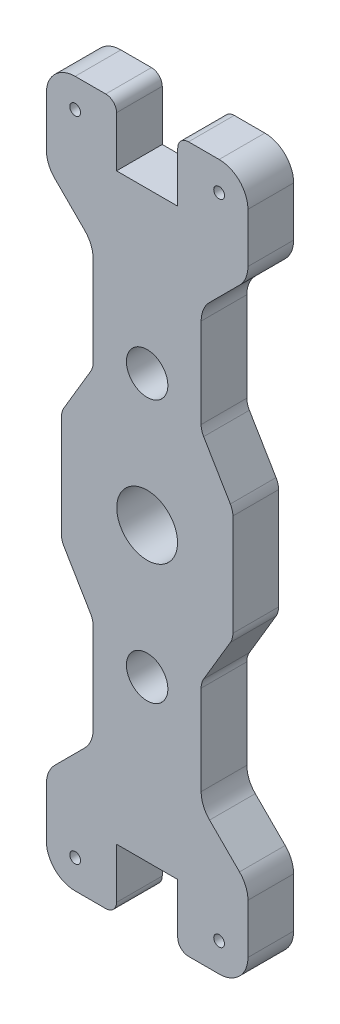
from build123d import *

# Parameters (mm, degrees)
SKETCH1_R                = 8.4375
SKETCH1_R_2              = 1.5
BOSS_EXTRUDE1_DEPTH      = 6.35
FILLET1_R                = 8
F_7_16_CLEARANCE_HOLE4_D = 11.50874
BOSS_EXTRUDE2_DEPTH      = 12.7
FILLET2_R                = 5


with BuildPart() as part:
    # Sketch1 → Boss-Extrude1 (new body, symmetric)
    with BuildSketch(Plane.XY):
        with BuildLine():
            Line((-28, 72.922835534), (-28, 90))
            ThreePointArc((-28, 90), (-25.656854249, 95.656854249), (-20, 98))
            Line((-20, 98), (-11.5, 98))
            ThreePointArc((-11.5, 98), (-9.378679656, 97.121320344), (-8.5, 95))
            Line((-8.5, 95), (-8.5, 81))
            Line((-8.5, 81), (8.5, 81))
            Line((8.5, 81), (8.5, 95))
            ThreePointArc((8.5, 95), (9.378679656, 97.121320344), (11.5, 98))
            Line((11.5, 98), (20, 98))
            ThreePointArc((20, 98), (25.656854249, 95.656854249), (28, 90))
            Line((28, 90), (28, 72.922835534))
            Line((28, 72.922835534), (15, 59.922835534))
            Line((15, 59.922835534), (15, -59.922835534))
            Line((15, -59.922835534), (28, -72.922835534))
            Line((28, -72.922835534), (28, -90))
            ThreePointArc((28, -90), (25.656854249, -95.656854249), (20, -98))
            Line((20, -98), (11.5, -98))
            ThreePointArc((11.5, -98), (9.378679656, -97.121320344), (8.5, -95))
            Line((8.5, -95), (8.5, -81))
            Line((8.5, -81), (-8.5, -81))
            Line((-8.5, -81), (-8.5, -95))
            ThreePointArc((-8.5, -95), (-9.378679656, -97.121320344), (-11.5, -98))
            Line((-11.5, -98), (-20, -98))
            ThreePointArc((-20, -98), (-25.656854249, -95.656854249), (-28, -90))
            Line((-28, -90), (-28, -72.922835534))
            Line((-28, -72.922835534), (-15, -59.922835534))
            Line((-15, -59.922835534), (-15, 59.922835534))
            Line((-15, 59.922835534), (-28, 72.922835534))
        make_face()
        Circle(SKETCH1_R, mode=Mode.SUBTRACT)
        with Locations((-20, 90)):
            Circle(SKETCH1_R_2, mode=Mode.SUBTRACT)
        with Locations((20, 90)):
            Circle(SKETCH1_R_2, mode=Mode.SUBTRACT)
        with Locations((20, -90)):
            Circle(SKETCH1_R_2, mode=Mode.SUBTRACT)
        with Locations((-20, -90)):
            Circle(SKETCH1_R_2, mode=Mode.SUBTRACT)
    extrude(amount=BOSS_EXTRUDE1_DEPTH, both=True)

    # Fillet1
    fillet1_edges = [part.edges().sort_by_distance(p)[0] for p in [
        (-28, 72.922835534, 0),
        (28, 72.922835534, 0),
        (15, 59.922835534, 0),
        (15, -59.922835534, 0),
        (28, -72.922835534, 0),
        (-28, -72.922835534, 0),
        (-15, -59.922835534, 0),
        (-15, 59.922835534, 0),
    ]]
    fillet(fillet1_edges, radius=FILLET1_R)

    # 7/16 Clearance Hole4 (through all)
    with Locations(Plane.XY.offset(6.35)):
        with Locations((0, 36.5125), (0, -36.5125)):
            Hole(F_7_16_CLEARANCE_HOLE4_D / 2)

    # Sketch6 → Boss-Extrude2 (add)
    with BuildSketch(Plane.XY.offset(6.35)):
        Polygon((-15, 30.340959615), (-23.8125, 15.4813), (-23.8125, -15.4813), (-15, -30.340959615), align=None)
        Polygon((23.8125, -15.4813), (15, -30.340959615), (15, 30.340959615), (23.8125, 15.4813), align=None)
    extrude(amount=-BOSS_EXTRUDE2_DEPTH)

    # Fillet2
    fillet2_edges = [part.edges().sort_by_distance(p)[0] for p in [
        (-23.8125, 15.4813, 0),
        (-23.8125, -15.4813, 0),
        (-15, -30.340959615, 0),
        (-15, 30.340959615, 0),
        (15, 30.340959615, 0),
        (15, -30.340959615, 0),
        (23.8125, -15.4813, 0),
        (23.8125, 15.4813, 0),
    ]]
    fillet(fillet2_edges, radius=FILLET2_R)


solid = part.part
